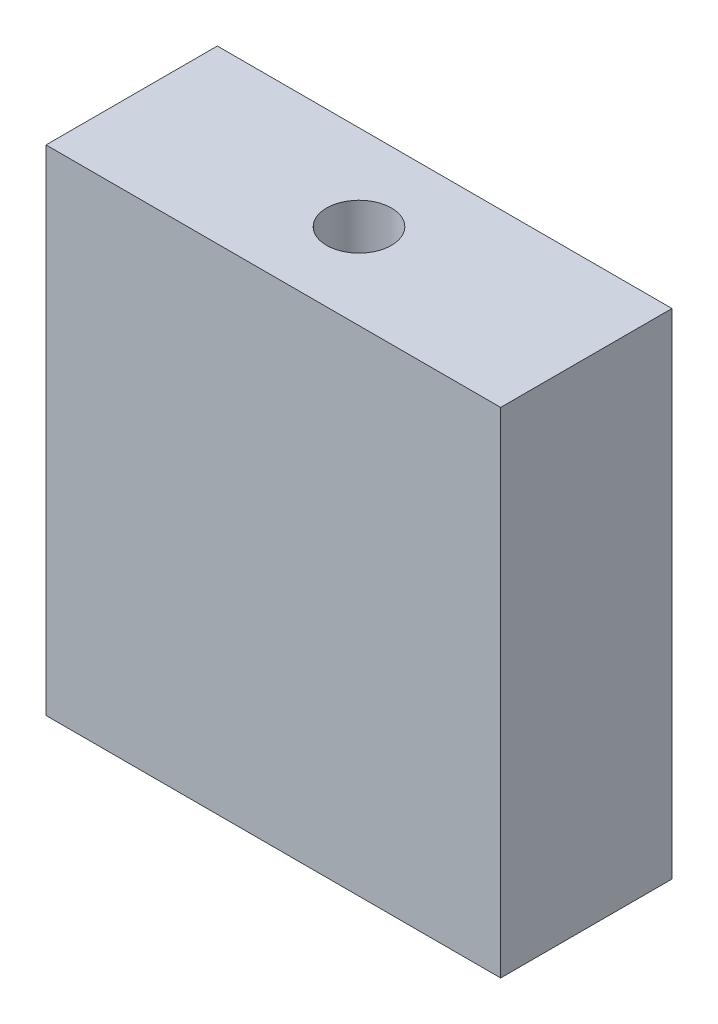
from build123d import *

# Parameters (mm, degrees)
SKETCH1_W                 = 17.526
SKETCH1_H                 = 19.05
BOSS_EXTRUDE1_DEPTH       = 6.604
M3X0_5_TAPPED_HOLE1_D     = 2.5
M3X0_5_TAPPED_HOLE1_DEPTH = 7.493
M3X0_5_TAPPED_HOLE1_TIP   = 0.751075774
M3X0_5_TAPPED_HOLE2_D     = 2.5
M3X0_5_TAPPED_HOLE2_DEPTH = 7.493
M3X0_5_TAPPED_HOLE2_TIP   = 0.751075774


with BuildPart() as part:
    # Sketch1 → Boss-Extrude1 (new body)
    with BuildSketch(Plane.XY):
        Rectangle(SKETCH1_W, SKETCH1_H)
    extrude(amount=BOSS_EXTRUDE1_DEPTH)

    # M3x0.5 Tapped Hole1
    with Locations(Plane(origin=(0, 9.525, 0), x_dir=(1, 0, 0), z_dir=(0, 1, 0))):
        with Locations((0, -3.302)):
            Hole(M3X0_5_TAPPED_HOLE1_D / 2, depth=M3X0_5_TAPPED_HOLE1_DEPTH)
            with Locations((0, 0, -(M3X0_5_TAPPED_HOLE1_DEPTH + M3X0_5_TAPPED_HOLE1_TIP / 2))):  # 118° drill point
                Cone(0, M3X0_5_TAPPED_HOLE1_D / 2, M3X0_5_TAPPED_HOLE1_TIP, mode=Mode.SUBTRACT)

    # M3x0.5 Tapped Hole2
    with Locations(Plane(origin=(0, -9.525, 0), x_dir=(-1, 0, 0), z_dir=(0, -1, 0))):
        with Locations((0, -3.302)):
            Hole(M3X0_5_TAPPED_HOLE2_D / 2, depth=M3X0_5_TAPPED_HOLE2_DEPTH)
            with Locations((0, 0, -(M3X0_5_TAPPED_HOLE2_DEPTH + M3X0_5_TAPPED_HOLE2_TIP / 2))):  # 118° drill point
                Cone(0, M3X0_5_TAPPED_HOLE2_D / 2, M3X0_5_TAPPED_HOLE2_TIP, mode=Mode.SUBTRACT)


solid = part.part
